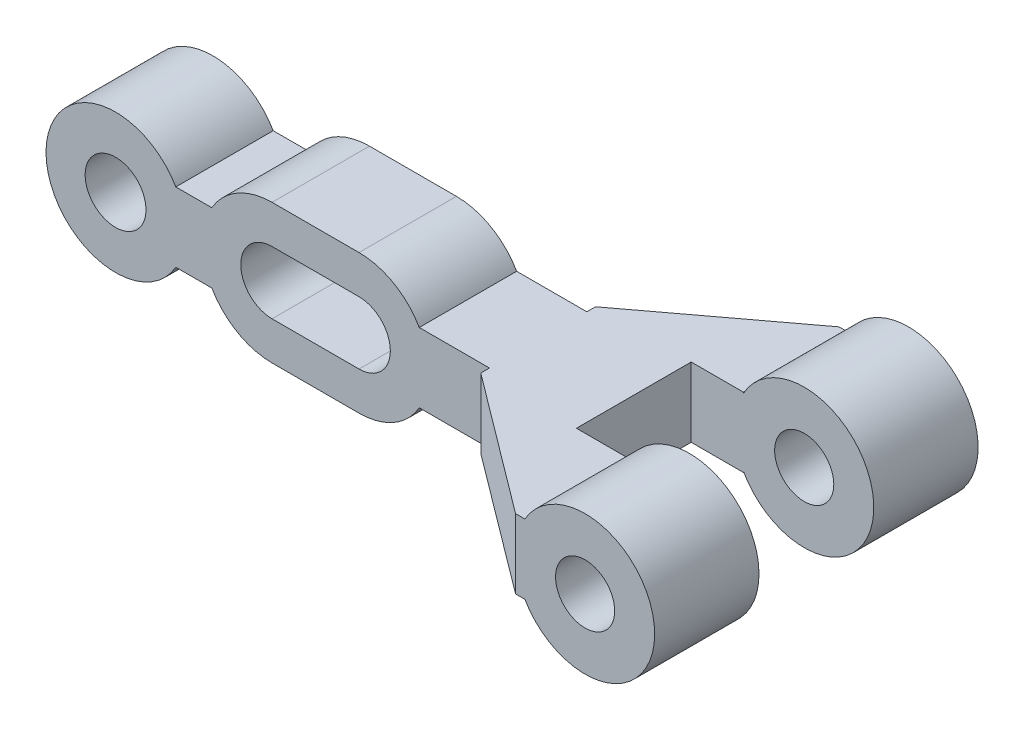
from build123d import *

# Parameters (mm, degrees)
SKETCH_1_R           = 4
SKETCH_1_R_2         = 1.7
EXTRUDE_1_DEPTH      = 6
EXTRUDE_2_DEPTH      = 2
EXTRUDE_2_DEPTH_BACK = 2
EXTRUDE_3_DEPTH      = 2.8
EXTRUDE_3_DEPTH_BACK = 2.8
SKETCH_3_R           = 1.75


with BuildPart() as part:
    # Эскиз1 → Бобышка-Вытянуть1 (new body)
    with BuildSketch(Plane.XY):
        Circle(SKETCH_1_R)
        Circle(SKETCH_1_R_2, mode=Mode.SUBTRACT)
    extrude_1 = extrude(amount=EXTRUDE_1_DEPTH)

    # Эскиз2 → Бобышка-Вытянуть2 (add, two sides: drawn at the far end of the back side and taken through both)
    with BuildSketch(Plane(origin=(0, 0, 0), x_dir=(1, 0, 0), z_dir=(0, 1, 0)).offset(-EXTRUDE_2_DEPTH_BACK)):
        Polygon((-4, 0), (-12, -6), (-12, -12.6), (-4, -18.6), (-3, -18.6), (-3, -12.6), (-4, -12.6), (-6.5, -12.6), (-6.5, -6), (-4, -6), (-3.5, -6), (-3.5, 0), align=None)
    extrude(amount=EXTRUDE_2_DEPTH + EXTRUDE_2_DEPTH_BACK)

    # Зеркальное отражение1: Бобышка-Вытянуть1 across plane
    add(extrude_1.mirror(Plane(origin=(0, 0, 9.3), x_dir=(1, 0, 0), z_dir=(0, 0, -1))))

    # Эскиз3 → Бобышка-Вытянуть3 (add, two sides: drawn at the far end of the back side and taken through both)
    with BuildSketch(Plane(origin=(0, 0, 9.3), x_dir=(-1, 0, 0), z_dir=(0, 0, -1)).offset(-EXTRUDE_3_DEPTH_BACK)):
        with BuildLine():
            Line((19.5, 4), (24.5, 4))
            ThreePointArc((24.5, 4), (26.5, 3.464101615), (27.964101615, 2))
            Line((27.964101615, 2), (30.035898385, 2))
            ThreePointArc((30.035898385, 2), (37.5, 0), (30.035898385, -2))
            Line((30.035898385, -2), (27.964101615, -2))
            ThreePointArc((27.964101615, -2), (26.5, -3.464101615), (24.5, -4))
            Line((24.5, -4), (19.5, -4))
            ThreePointArc((19.5, -4), (17.5, -3.464101615), (16.035898385, -2))
            Line((16.035898385, -2), (12, -2))
            Line((12, -2), (12, 2))
            Line((12, 2), (16.035898385, 2))
            ThreePointArc((16.035898385, 2), (17.5, 3.464101615), (19.5, 4))
        make_face()
        with Locations((33.5, 0)):
            Circle(SKETCH_3_R, mode=Mode.SUBTRACT)
        with BuildLine():
            Line((19.5, 1.8), (24.5, 1.8))
            ThreePointArc((24.5, 1.8), (26.3, 0), (24.5, -1.8))
            Line((24.5, -1.8), (19.5, -1.8))
            ThreePointArc((19.5, -1.8), (17.7, 0), (19.5, 1.8))
        make_face(mode=Mode.SUBTRACT)
    extrude(amount=EXTRUDE_3_DEPTH + EXTRUDE_3_DEPTH_BACK)


solid = part.part
